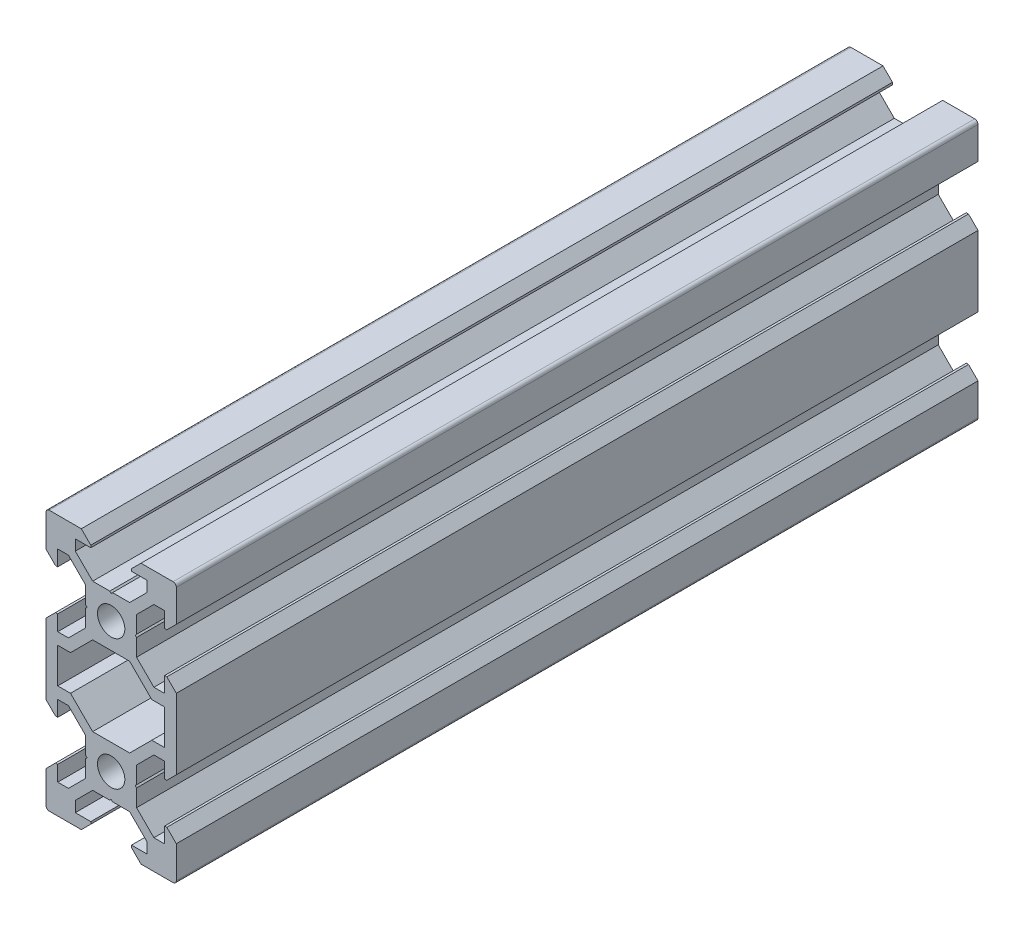
from build123d import *

# Parameters (mm, degrees)
SKETCH1_R           = 2.1
BOSS_EXTRUDE1_DEPTH = 123.05


with BuildPart() as part:
    # Sketch1 → Boss-Extrude1 (new body)
    with BuildSketch(Plane.XY):
        with BuildLine():
            Line((4.58, -20), (9.5, -20))
            ThreePointArc((9.5, -20), (9.853553391, -19.853553391), (10, -19.5))
            Line((10, -19.5), (10, -14.58))
            Line((10, -14.58), (8.545, -13.125))
            Line((8.545, -13.125), (8.2, -13.125))
            Line((8.2, -13.125), (8.2, -15.5))
            Line((8.2, -15.5), (6.560660172, -15.5))
            Line((6.560660172, -15.5), (3.9, -12.839339828))
            Line((3.9, -12.839339828), (3.9, -10.21))
            Line((3.9, -10.21), (3.69, -10))
            Line((3.69, -10), (3.9, -9.79))
            Line((3.9, -9.79), (3.9, -7.160660172))
            Line((3.9, -7.160660172), (6.560660172, -4.5))
            Line((6.560660172, -4.5), (8.2, -4.5))
            Line((8.2, -4.5), (8.2, -6.875))
            Line((8.2, -6.875), (8.545, -6.875))
            Line((8.545, -6.875), (10, -5.42))
            Line((10, -5.42), (10, 5.42))
            Line((10, 5.42), (8.545, 6.875))
            Line((8.545, 6.875), (8.2, 6.875))
            Line((8.2, 6.875), (8.2, 4.5))
            Line((8.2, 4.5), (6.560660172, 4.5))
            Line((6.560660172, 4.5), (3.9, 7.160660172))
            Line((3.9, 7.160660172), (3.9, 9.79))
            Line((3.9, 9.79), (3.69, 10))
            Line((3.69, 10), (3.9, 10.21))
            Line((3.9, 10.21), (3.9, 12.839339828))
            Line((3.9, 12.839339828), (6.560660172, 15.5))
            Line((6.560660172, 15.5), (8.2, 15.5))
            Line((8.2, 15.5), (8.2, 13.125))
            Line((8.2, 13.125), (8.545, 13.125))
            Line((8.545, 13.125), (10, 14.58))
            Line((10, 14.58), (10, 19.5))
            ThreePointArc((10, 19.5), (9.853553391, 19.853553391), (9.5, 20))
            Line((9.5, 20), (4.58, 20))
            Line((4.58, 20), (3.125, 18.545))
            Line((3.125, 18.545), (3.125, 18.2))
            Line((3.125, 18.2), (5.5, 18.2))
            Line((5.5, 18.2), (5.5, 16.560660172))
            Line((5.5, 16.560660172), (2.839339828, 13.9))
            Line((2.839339828, 13.9), (0.21, 13.9))
            Line((0.21, 13.9), (0, 13.69))
            Line((0, 13.69), (-0.21, 13.9))
            Line((-0.21, 13.9), (-2.839339828, 13.9))
            Line((-2.839339828, 13.9), (-5.5, 16.560660172))
            Line((-5.5, 16.560660172), (-5.5, 18.2))
            Line((-5.5, 18.2), (-3.125, 18.2))
            Line((-3.125, 18.2), (-3.125, 18.545))
            Line((-3.125, 18.545), (-4.58, 20))
            Line((-4.58, 20), (-9.5, 20))
            ThreePointArc((-9.5, 20), (-9.853553391, 19.853553391), (-10, 19.5))
            Line((-10, 19.5), (-10, 14.58))
            Line((-10, 14.58), (-8.545, 13.125))
            Line((-8.545, 13.125), (-8.2, 13.125))
            Line((-8.2, 13.125), (-8.2, 15.5))
            Line((-8.2, 15.5), (-6.560660172, 15.5))
            Line((-6.560660172, 15.5), (-3.9, 12.839339828))
            Line((-3.9, 12.839339828), (-3.9, 10.21))
            Line((-3.9, 10.21), (-3.69, 10))
            Line((-3.69, 10), (-3.9, 9.79))
            Line((-3.9, 9.79), (-3.9, 7.160660172))
            Line((-3.9, 7.160660172), (-6.560660172, 4.5))
            Line((-6.560660172, 4.5), (-8.2, 4.5))
            Line((-8.2, 4.5), (-8.2, 6.875))
            Line((-8.2, 6.875), (-8.545, 6.875))
            Line((-8.545, 6.875), (-10, 5.42))
            Line((-10, 5.42), (-10, -5.42))
            Line((-10, -5.42), (-8.545, -6.875))
            Line((-8.545, -6.875), (-8.2, -6.875))
            Line((-8.2, -6.875), (-8.2, -4.5))
            Line((-8.2, -4.5), (-6.560660172, -4.5))
            Line((-6.560660172, -4.5), (-3.9, -7.160660172))
            Line((-3.9, -7.160660172), (-3.9, -9.79))
            Line((-3.9, -9.79), (-3.69, -10))
            Line((-3.69, -10), (-3.9, -10.21))
            Line((-3.9, -10.21), (-3.9, -12.839339828))
            Line((-3.9, -12.839339828), (-6.560660172, -15.5))
            Line((-6.560660172, -15.5), (-8.2, -15.5))
            Line((-8.2, -15.5), (-8.2, -13.125))
            Line((-8.2, -13.125), (-8.545, -13.125))
            Line((-8.545, -13.125), (-10, -14.58))
            Line((-10, -14.58), (-10, -19.5))
            ThreePointArc((-10, -19.5), (-9.853553391, -19.853553391), (-9.5, -20))
            Line((-9.5, -20), (-4.58, -20))
            Line((-4.58, -20), (-3.125, -18.545))
            Line((-3.125, -18.545), (-3.125, -18.2))
            Line((-3.125, -18.2), (-5.5, -18.2))
            Line((-5.5, -18.2), (-5.5, -16.560660172))
            Line((-5.5, -16.560660172), (-2.839339828, -13.9))
            Line((-2.839339828, -13.9), (-0.21, -13.9))
            Line((-0.21, -13.9), (0, -13.69))
            Line((0, -13.69), (0.21, -13.9))
            Line((0.21, -13.9), (2.839339828, -13.9))
            Line((2.839339828, -13.9), (5.5, -16.560660172))
            Line((5.5, -16.560660172), (5.5, -18.2))
            Line((5.5, -18.2), (3.125, -18.2))
            Line((3.125, -18.2), (3.125, -18.545))
            Line((3.125, -18.545), (4.58, -20))
        make_face()
        with Locations((0, -10)):
            Circle(SKETCH1_R, mode=Mode.SUBTRACT)
        Polygon((-6.239339828, -2.7), (-8.2, -2.7), (-8.2, 2.7), (-6.239339828, 2.7), (-2.839339828, 6.1), (2.839339828, 6.1), (6.239339828, 2.7), (8.2, 2.7), (8.2, -2.7), (6.239339828, -2.7), (2.839339828, -6.1), (-2.839339828, -6.1), align=None, mode=Mode.SUBTRACT)
        with Locations((0, 10)):
            Circle(SKETCH1_R, mode=Mode.SUBTRACT)
    extrude(amount=BOSS_EXTRUDE1_DEPTH)


solid = part.part
